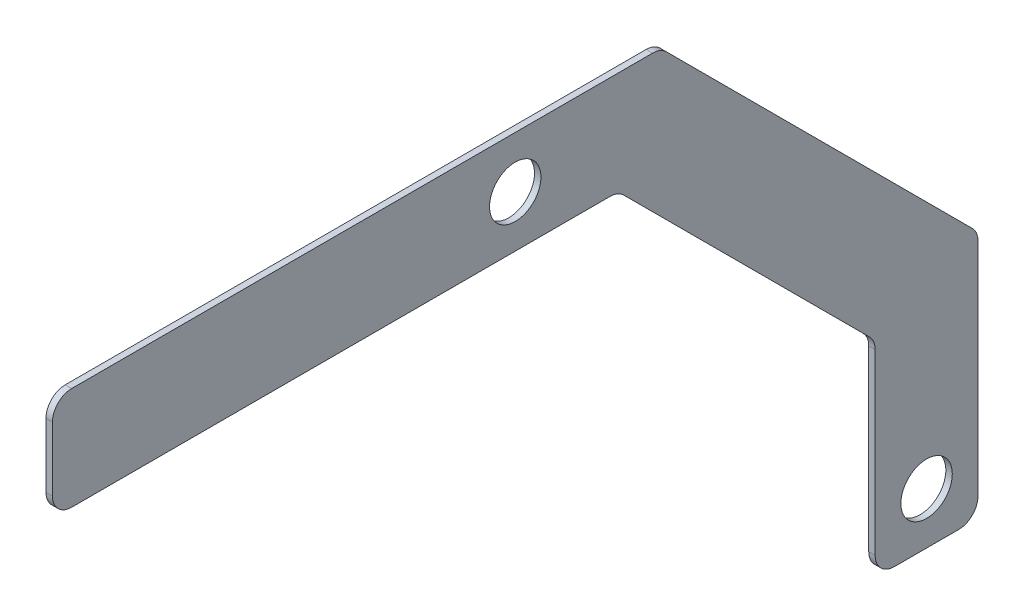
from build123d import *

# Parameters (mm, degrees)
SKETCH1_R           = 12.7
BOSS_EXTRUDE1_DEPTH = 3.175
SKETCH3_R           = 12.7
CUT_EXTRUDE1_DEPTH  = 4.175
SKETCH4_W           = 50.8
SKETCH4_H           = 228.6
CUT_EXTRUDE2_DEPTH  = 4.175
BOSS_EXTRUDE2_DEPTH = 3.175
CUT_EXTRUDE3_DEPTH  = 4.175
FILLET1_R           = 9.525


with BuildPart() as part:
    # Sketch1 → Boss-Extrude1 (new body)
    with BuildSketch(Plane(origin=(0, 0, 0), x_dir=(0, 0, -1), z_dir=(1, 0, 0))):
        Polygon((-228.6, 25.4), (228.6, 25.4), (228.6, -254), (177.8, -254), (177.8, -25.4), (-177.8, -25.4), (-177.8, -254), (-228.6, -254), align=None)
        Circle(SKETCH1_R, mode=Mode.SUBTRACT)
    extrude(amount=BOSS_EXTRUDE1_DEPTH)

    # Sketch3 → Cut-Extrude1 (cut, through all)
    with BuildSketch(Plane(origin=(3.175, 0, 0), x_dir=(0, 0, -1), z_dir=(1, 0, 0))):
        with Locations((-203.2, -228.6)):
            Circle(SKETCH3_R)
        with Locations((203.2, -228.6)):
            Circle(SKETCH3_R)
    extrude(amount=-CUT_EXTRUDE1_DEPTH, mode=Mode.SUBTRACT)

    # Sketch4 → Cut-Extrude2 (cut, through all)
    with BuildSketch(Plane(origin=(3.175, 0, 0), x_dir=(0, 0, -1), z_dir=(1, 0, 0))):
        with Locations((-203.2, -139.7)):
            Rectangle(SKETCH4_W, SKETCH4_H)
    extrude(amount=-CUT_EXTRUDE2_DEPTH, mode=Mode.SUBTRACT)

    # Sketch5 → Boss-Extrude2 (add)
    with BuildSketch(Plane(origin=(3.175, 0, 0), x_dir=(0, 0, -1), z_dir=(1, 0, 0))):
        Polygon((50.8, -25.4), (177.8, -152.4), (177.8, -25.4), align=None)
    extrude(amount=-BOSS_EXTRUDE2_DEPTH)

    # Sketch6 → Cut-Extrude3 (cut, through all)
    with BuildSketch(Plane(origin=(3.175, 0, 0), x_dir=(0, 0, -1), z_dir=(1, 0, 0))):
        Polygon((71.842048969, 25.4), (228.6, -131.357951031), (228.6, 25.4), align=None)
    extrude(amount=-CUT_EXTRUDE3_DEPTH, mode=Mode.SUBTRACT)

    # Fillet1
    fillet1_edges = [part.edges().sort_by_distance(p)[0] for p in [
        (1.5875, 25.4, 228.6),
        (1.5875, -254, -228.6),
        (1.5875, -254, -177.8),
        (1.5875, -25.4, 228.6),
        (1.5875, -25.4, -50.8),
        (1.5875, -152.4, -177.8),
        (1.5875, 25.4, -71.842048969),
        (1.5875, -131.357951031, -228.6),
    ]]
    fillet(fillet1_edges, radius=FILLET1_R)


solid = part.part
